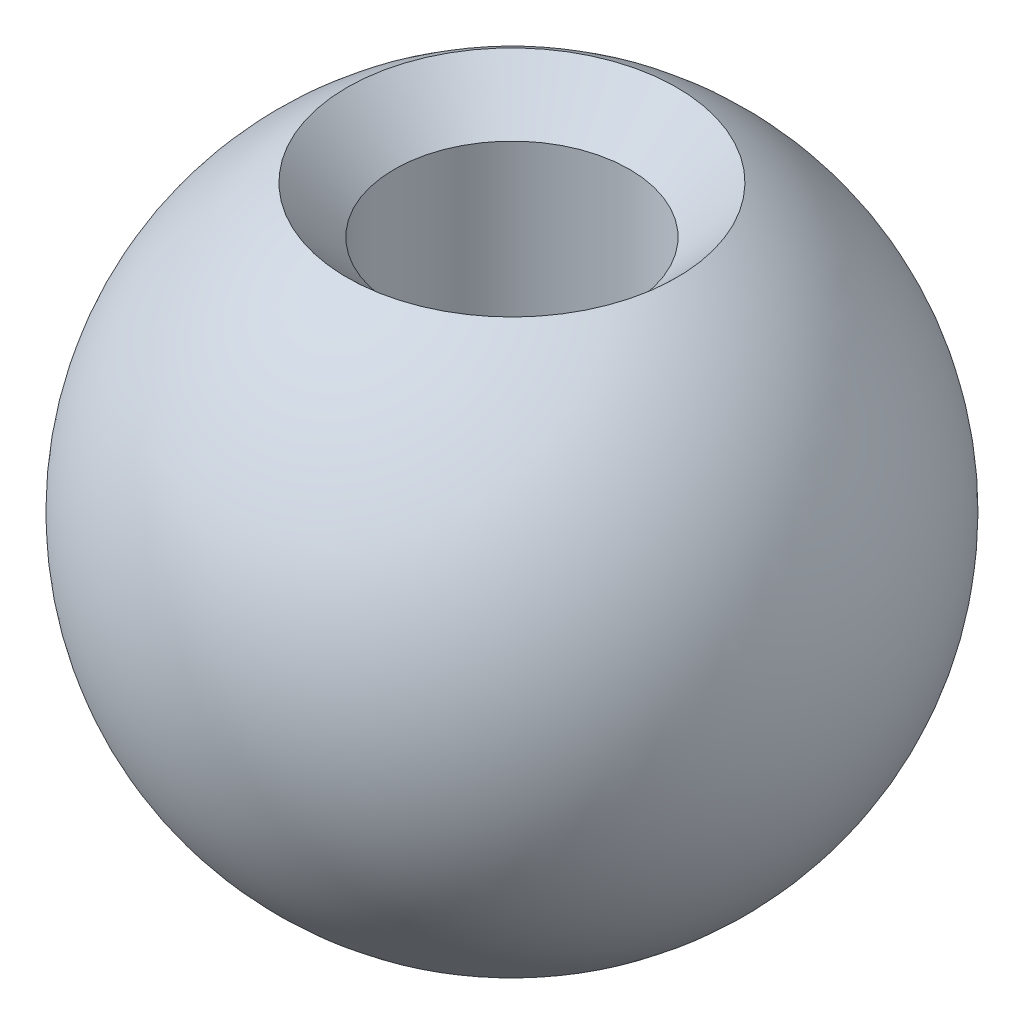
from build123d import *


with BuildPart() as part:
    # Sketch1 → Revolve2 (revolve)
    with BuildSketch(Plane.XY):
        with BuildLine():
            Line((1.9812, 4.01492865), (1.9812, -5.191026933))
            ThreePointArc((1.9812, -5.191026933), (5.538700082, -0.441265746), (2.778125, 4.81185365))
            Line((2.778125, 4.81185365), (1.9812, 4.01492865))
        make_face()
    revolve(axis=Axis((0, 9.617404058, 0), (0, -1, 0)))


solid = part.part
